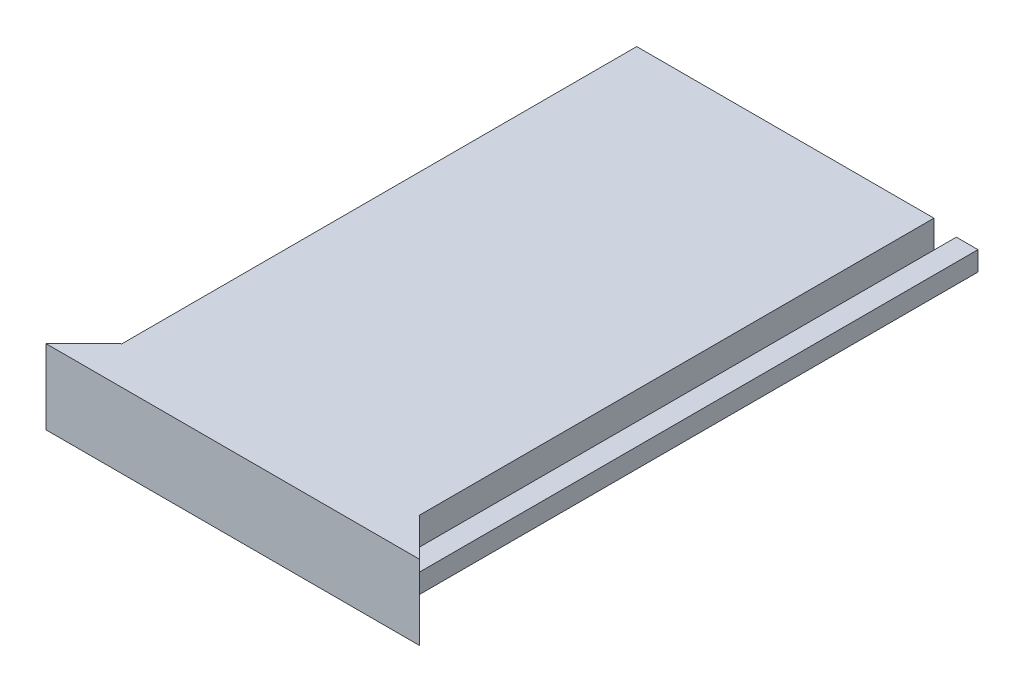
from build123d import *

# Parameters (mm, degrees)
SKETCH1_W               = 50
SKETCH1_H               = 10
BOSS_EXTRUDE1_DEPTH     = 5
CUT_EXTRUDE1_DEPTH      = 6
CUT_EXTRUDE1_DEPTH_BACK = 6
SKETCH3_W               = 45.6
SKETCH3_H               = 2.6
BOSS_EXTRUDE2_DEPTH     = 77
SKETCH4_W               = 39.8
SKETCH4_H               = 72
CUT_EXTRUDE2_DEPTH      = 77
BOSS_EXTRUDE3_DEPTH     = 72
SKETCH7_W               = 39.8
SKETCH7_H               = 3
CUT_EXTRUDE3_DEPTH      = 10


with BuildPart() as part:
    # Sketch1 → Boss-Extrude1 (new body)
    with BuildSketch(Plane.XY):
        Rectangle(SKETCH1_W, SKETCH1_H)
    extrude(amount=BOSS_EXTRUDE1_DEPTH)

    # Sketch2 → Cut-Extrude1 (cut, two sides)
    with BuildSketch(Plane(origin=(0, 0, 0), x_dir=(1, 0, 0), z_dir=(0, 1, 0))) as cut_extrude1_sk:
        Polygon((-25, -5), (-20, 0), (-25, 0), align=None)
        Polygon((25, -5), (20, 0), (25, 0), align=None)
    extrude(amount=CUT_EXTRUDE1_DEPTH, mode=Mode.SUBTRACT)
    extrude(cut_extrude1_sk.sketch, amount=-CUT_EXTRUDE1_DEPTH_BACK, mode=Mode.SUBTRACT)

    # Sketch3 → Boss-Extrude2 (add)
    with BuildSketch(Plane.XY.offset(5)):
        Rectangle(SKETCH3_W, SKETCH3_H)
    extrude(amount=-BOSS_EXTRUDE2_DEPTH)

    # Sketch4 → Cut-Extrude2 (cut)
    with BuildSketch(Plane(origin=(0, 1.3, 0), x_dir=(1, 0, 0), z_dir=(0, 1, 0))):
        with Locations((0, 36)):
            Rectangle(SKETCH4_W, SKETCH4_H)
    extrude(amount=-CUT_EXTRUDE2_DEPTH, mode=Mode.SUBTRACT)

    # Sketch6 → Boss-Extrude3 (add)
    with BuildSketch(Plane(origin=(0, 0, 0), x_dir=(-1, 0, 0), z_dir=(0, 0, -1))):
        Polygon((-19.9, -1.3), (-19.9, 5), (19.9, 5), (19.9, -1.3), (18.4, -1.3), (18.4, 3), (-18.4, 3), (-18.4, -1.3), align=None)
    extrude(amount=BOSS_EXTRUDE3_DEPTH)

    # Sketch7 → Cut-Extrude3 (cut)
    with BuildSketch(Plane(origin=(0, 5, 0), x_dir=(1, 0, 0), z_dir=(0, 1, 0))):
        with Locations((0, 70.5)):
            Rectangle(SKETCH7_W, SKETCH7_H)
    extrude(amount=-CUT_EXTRUDE3_DEPTH, mode=Mode.SUBTRACT)


solid = part.part
